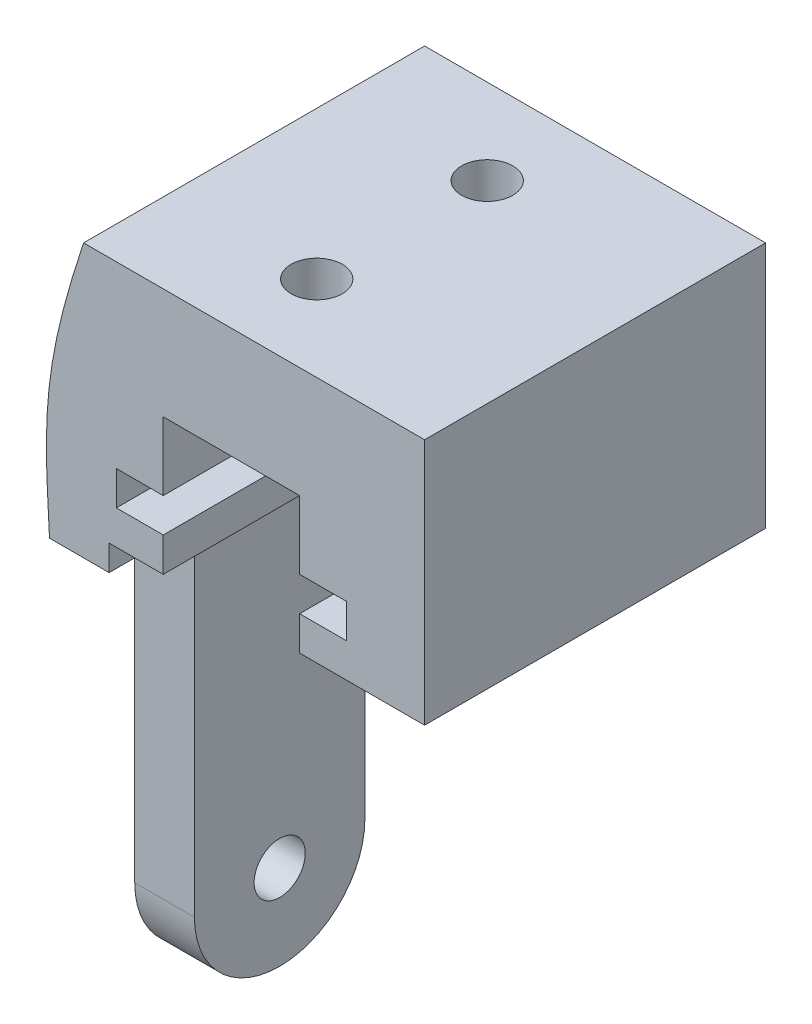
from build123d import *

# Parameters (mm, degrees)
BOSS_EXTRUDE1_DEPTH = 20
SKETCH2_R           = 1.5
CUT_EXTRUDE1_DEPTH  = 6.5
SKETCH4_W           = 3.5
SKETCH4_H           = 10
BOSS_EXTRUDE2_DEPTH = 20
BOSS_EXTRUDE3_DEPTH = 3.5
SKETCH6_R           = 1.5
CUT_EXTRUDE2_DEPTH  = 20


with BuildPart() as part:
    # Sketch1 → Boss-Extrude1 (new body)
    with BuildSketch(Plane.XY):
        with BuildLine():
            Line((-10, 0), (10, 0))
            Line((10, 0), (10, -14.5))
            Line((10, -14.5), (2.672015421, -14.5))
            Line((2.672015421, -14.5), (2.672015421, -12.5))
            Line((2.672015421, -12.5), (5.422015421, -12.5))
            Line((5.422015421, -12.5), (5.422015421, -10.5))
            Line((5.422015421, -10.5), (2.672015421, -10.5))
            Line((2.672015421, -10.5), (2.672015421, -6.5))
            Line((2.672015421, -6.5), (-5.327984579, -6.5))
            Line((-5.327984579, -6.5), (-5.327984579, -10.5))
            Line((-5.327984579, -10.5), (-8.077984579, -10.5))
            Line((-8.077984579, -10.5), (-8.077984579, -12.5))
            Line((-8.077984579, -12.5), (-5.327984579, -12.5))
            Line((-5.327984579, -12.5), (-5.327984579, -14.5))
            Line((-5.327984579, -14.5), (-8.5, -14.5))
            Line((-8.5, -14.5), (-8.5, -16))
            Line((-8.5, -16), (-12, -16))
            add(Edge.make_bspline(
                [(-10, 0), (-12.576646285, -7.740566288), (-12.284280687, -10.492382976), (-12, -16)],
                knots=[0, 0, 0, 0, 1, 1, 1, 1], degree=3))
        make_face()
    extrude(amount=BOSS_EXTRUDE1_DEPTH)

    # Sketch2 → Cut-Extrude1 (cut)
    with BuildSketch(Plane.XZ.offset(6.5)):
        with Locations((-1.327984579, 15)):
            Circle(SKETCH2_R)
        with Locations((-1.327984579, 5)):
            Circle(SKETCH2_R)
    extrude(amount=-CUT_EXTRUDE1_DEPTH, mode=Mode.SUBTRACT)

    # Sketch4 → Boss-Extrude2 (add)
    with BuildSketch(Plane.XZ.offset(16)):
        with Locations((-10.25, 10)):
            Rectangle(SKETCH4_W, SKETCH4_H)
    extrude(amount=BOSS_EXTRUDE2_DEPTH)

    # Sketch5 → Boss-Extrude3 (add)
    with BuildSketch(Plane.ZY.offset(12)):
        with BuildLine():
            Line((5, -36), (15, -36))
            ThreePointArc((15, -36), (10, -41), (5, -36))
        make_face()
    extrude(amount=-BOSS_EXTRUDE3_DEPTH)

    # Sketch6 → Cut-Extrude2 (cut)
    with BuildSketch(Plane.ZY.offset(12)):
        with Locations((10, -36)):
            Circle(SKETCH6_R)
    extrude(amount=-CUT_EXTRUDE2_DEPTH, mode=Mode.SUBTRACT)


solid = part.part
